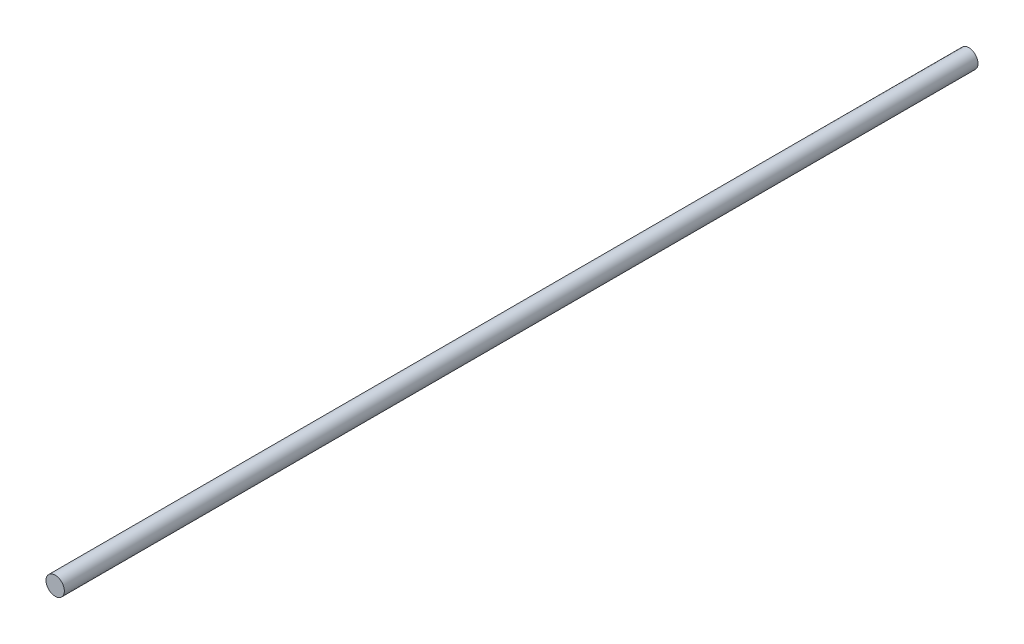
from build123d import *

# Parameters (mm, degrees)
ESBO_O1_R                = 3.97
RESSALTO_EXTRUS_O1_DEPTH = 197.5


with BuildPart() as part:
    # Esboço1 → Ressalto-extrusão1 (new body, symmetric)
    with BuildSketch(Plane.XY):
        Circle(ESBO_O1_R)
    extrude(amount=RESSALTO_EXTRUS_O1_DEPTH, both=True)


solid = part.part
